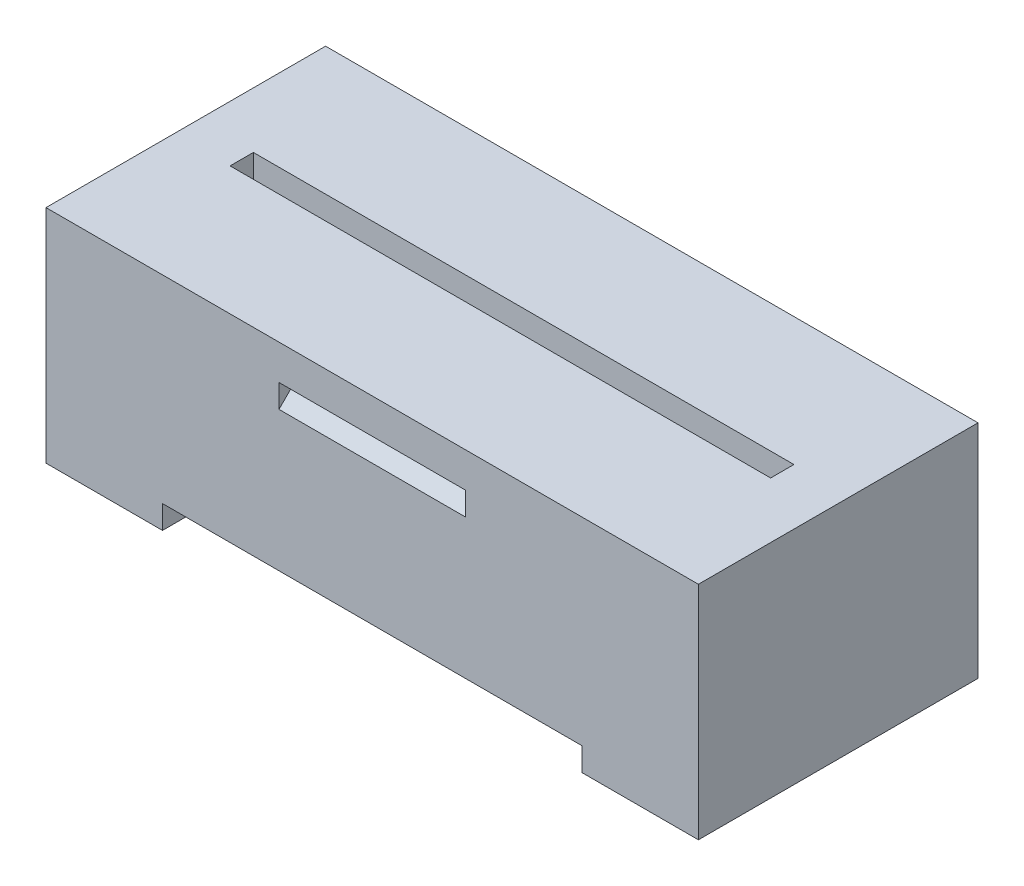
from build123d import *

# Parameters (mm, degrees)
SKICA1_W                 = 28
SKICA1_H                 = 8.5
P_IDAT_VYSUNUT_M1_DEPTH  = 12
SKICA3_R                 = 2.6
ODEBRAT_VYSUNUT_M2_DEPTH = 7.5
SKICA4_W                 = 23.2
SKICA4_H                 = 1
ODEBRAT_VYSUNUT_M3_DEPTH = 1
SKICA5_W                 = 5
SKICA5_H                 = 12
P_IDAT_VYSUNUT_M2_DEPTH  = 1
SKICA6_W                 = 4
SKICA6_H                 = 10
ODEBRAT_VYSUNUT_M4_DEPTH = 1
ODEBRAT_START            = -10
ODEBRAT_VYSUNUT_M5_DEPTH = 8


with BuildPart() as part:
    # Skica1 → Přidat vysunutím1 (new body)
    with BuildSketch(Plane.XY):
        with Locations((-32.656744291, -2.464704976)):
            Rectangle(SKICA1_W, SKICA1_H)
    extrude(amount=P_IDAT_VYSUNUT_M1_DEPTH)

    # Skica3 → Odebrat vysunutím2 (cut)
    with BuildSketch(Plane(origin=(0, -6.714704976, 0), x_dir=(-1, 0, 0), z_dir=(0, -1, 0))):
        with Locations((41.656744291, -6)):
            Circle(SKICA3_R)
        with Locations((35.646744291, -6)):
            Circle(SKICA3_R)
        with Locations((29.636744291, -6)):
            Circle(SKICA3_R)
        with Locations((23.626744291, -6)):
            Circle(SKICA3_R)
    extrude(amount=-ODEBRAT_VYSUNUT_M2_DEPTH, mode=Mode.SUBTRACT)

    # Skica4 → Odebrat vysunutím3 (cut)
    with BuildSketch(Plane(origin=(0, 1.785295024, 0), x_dir=(1, 0, 0), z_dir=(0, 1, 0))):
        with Locations((-32.656744291, -6)):
            Rectangle(SKICA4_W, SKICA4_H)
    extrude(amount=-ODEBRAT_VYSUNUT_M3_DEPTH, mode=Mode.SUBTRACT)

    # Skica5 → Přidat vysunutím2 (add)
    with BuildSketch(Plane(origin=(0, -6.714704976, 0), x_dir=(-1, 0, 0), z_dir=(0, -1, 0))):
        with Locations((44.156744291, -6)):
            Rectangle(SKICA5_W, SKICA5_H)
        with Locations((21.156744291, -6)):
            Rectangle(SKICA5_W, SKICA5_H)
    extrude(amount=P_IDAT_VYSUNUT_M2_DEPTH)

    # Skica6 → Odebrat vysunutím4 (cut)
    with BuildSketch(Plane(origin=(0, -7.714704976, 0), x_dir=(-1, 0, 0), z_dir=(0, -1, 0))):
        with Locations((43.656744291, -6)):
            Rectangle(SKICA6_W, SKICA6_H)
        with Locations((21.656744291, -6)):
            Rectangle(SKICA6_W, SKICA6_H)
    extrude(amount=-ODEBRAT_VYSUNUT_M4_DEPTH, mode=Mode.SUBTRACT)

    # Skica9 → Odebrat vysunutím5 (cut)
    with BuildSketch(Plane(origin=(-18.656744291, 0, 0), x_dir=(0, 0, -1), z_dir=(1, 0, 0)).offset(ODEBRAT_START)):
        Polygon((-12, 0.285295024), (-11, 0.285295024), (-12, -0.714704976), align=None)
        Polygon((0, 0.285295024), (-1, 0.285295024), (0, -0.714704976), align=None)
    extrude(amount=-ODEBRAT_VYSUNUT_M5_DEPTH, mode=Mode.SUBTRACT)


solid = part.part
